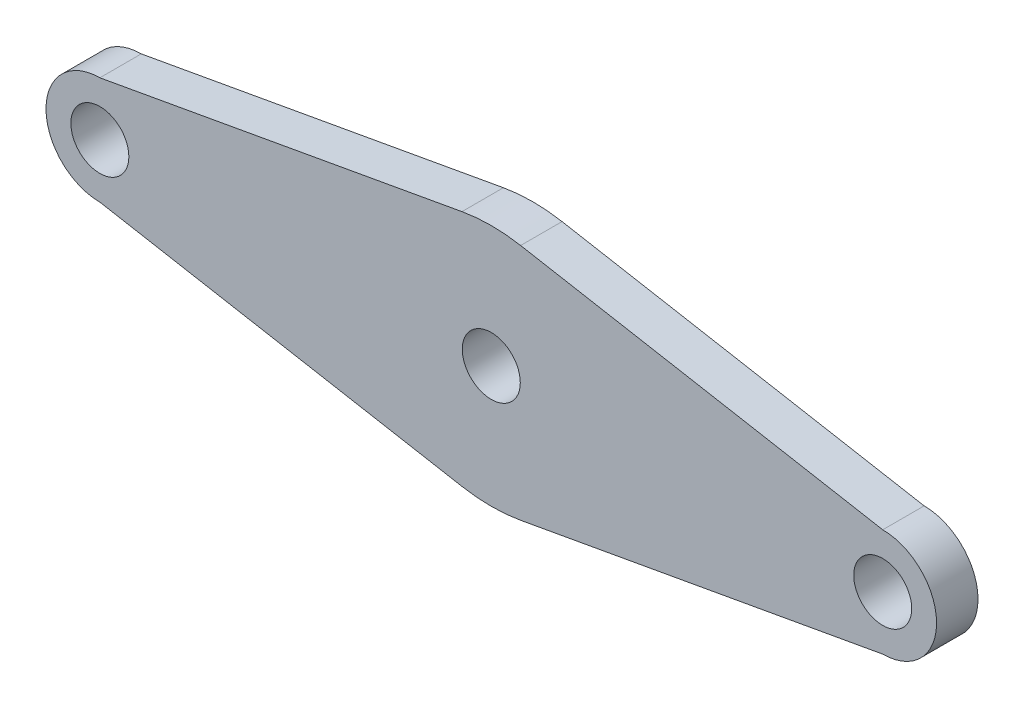
from build123d import *

# Parameters (mm, degrees)
SKETCH1_R           = 1.75
BOSS_EXTRUDE1_DEPTH = 2.5
FILLET1_R           = 10


with BuildPart() as part:
    # Sketch1 → Boss-Extrude1 (new body)
    with BuildSketch(Plane.XY):
        with BuildLine():
            ThreePointArc((-23.625, 3.25), (-26.875, 0), (-23.625, -3.25))
            Line((-23.625, -3.25), (0, -7.5))
            Line((0, -7.5), (23.625, -3.25))
            ThreePointArc((23.625, -3.25), (26.875, 0), (23.625, 3.25))
            Line((23.625, 3.25), (0, 7.5))
            Line((0, 7.5), (-23.625, 3.25))
        make_face()
        with Locations((-23.625, 0)):
            Circle(SKETCH1_R, mode=Mode.SUBTRACT)
        Circle(SKETCH1_R, mode=Mode.SUBTRACT)
        with Locations((23.625, 0)):
            Circle(SKETCH1_R, mode=Mode.SUBTRACT)
    extrude(amount=BOSS_EXTRUDE1_DEPTH)

    # Fillet1
    fillet1_edges = [part.edges().sort_by_distance(p)[0] for p in [
        (0, -7.5, 1.25),
        (0, 7.5, 1.25),
    ]]
    fillet(fillet1_edges, radius=FILLET1_R)


solid = part.part
